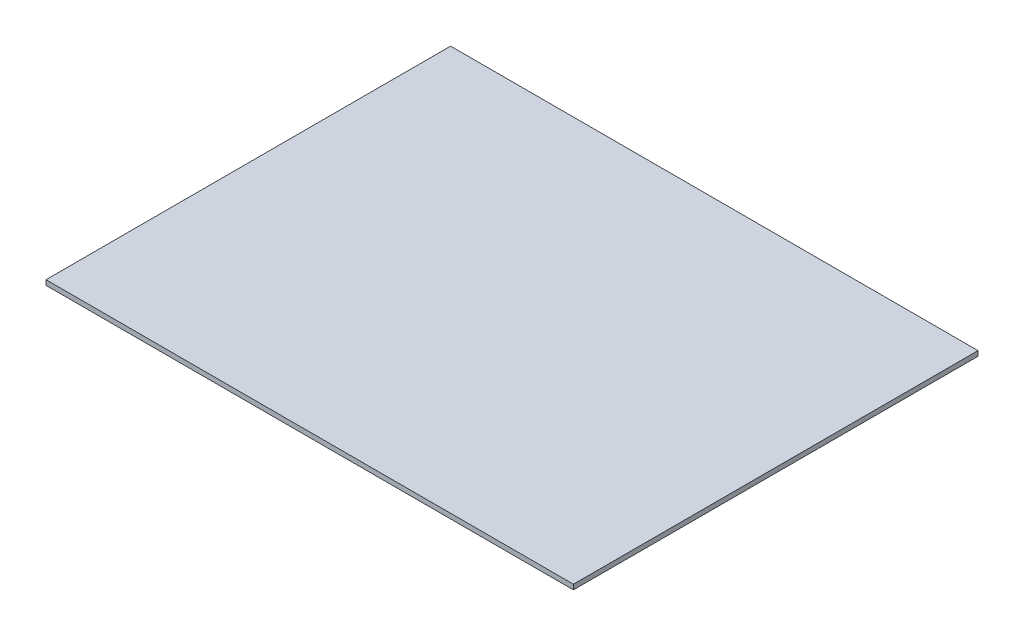
from build123d import *

# Parameters (mm, degrees)
CROQUIS1_W              = 322
CROQUIS1_H              = 247
SALIENTE_EXTRUIR1_DEPTH = 3


with BuildPart() as part:
    # Croquis1 → Saliente-Extruir1 (new body)
    with BuildSketch(Plane(origin=(0, 0, 0), x_dir=(1, 0, 0), z_dir=(0, 1, 0))):
        Rectangle(CROQUIS1_W, CROQUIS1_H)
    extrude(amount=SALIENTE_EXTRUIR1_DEPTH)


solid = part.part
